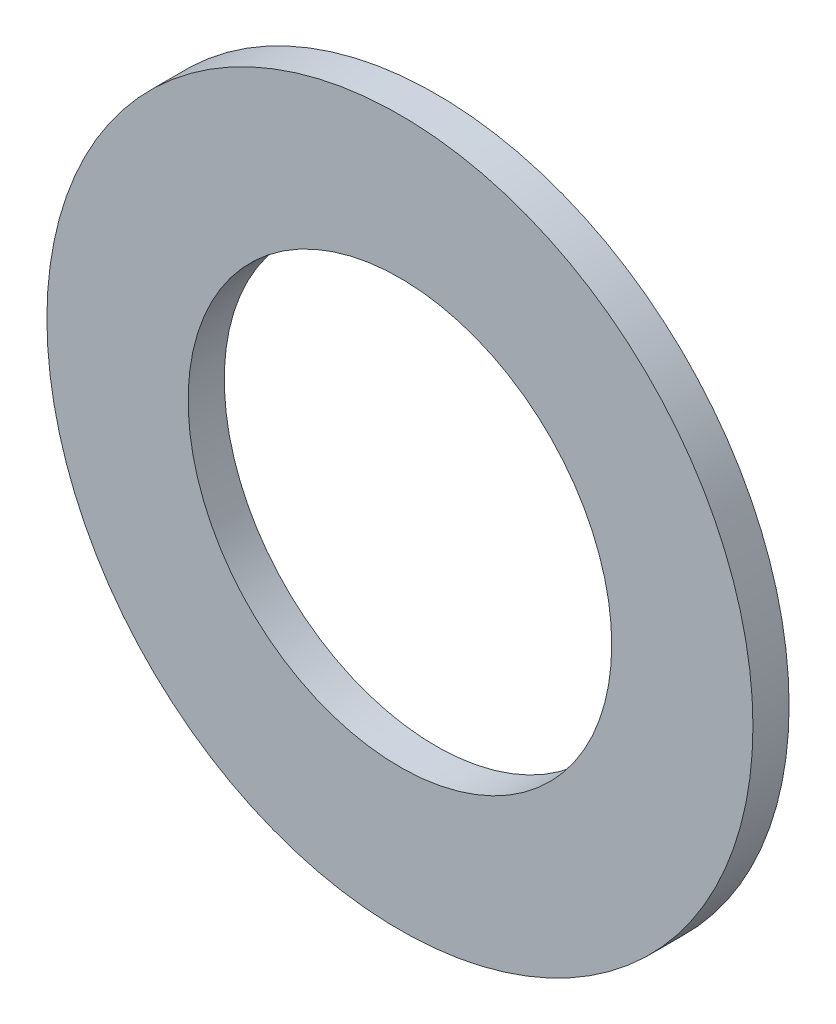
from build123d import *

# Parameters (mm, degrees)
SKETCH1_R           = 7.9375
SKETCH1_R_2         = 4.7625
BOSS_EXTRUDE1_DEPTH = 0.8128


with BuildPart() as part:
    # Sketch1 → Boss-Extrude1 (new body)
    with BuildSketch(Plane.XY):
        Circle(SKETCH1_R)
        Circle(SKETCH1_R_2, mode=Mode.SUBTRACT)
    extrude(amount=BOSS_EXTRUDE1_DEPTH)


solid = part.part
